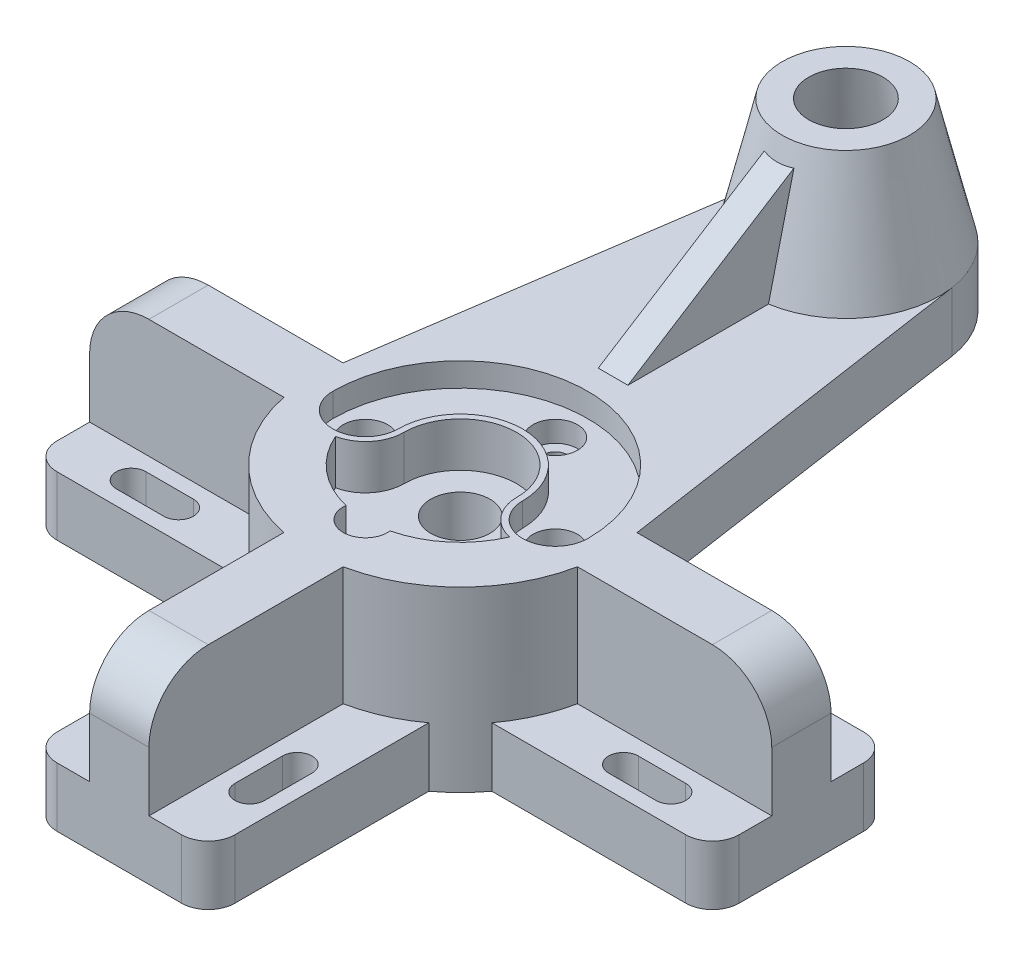
from build123d import *

# Parameters (mm, degrees)
SKETCH1_R                                     = 50.5
BOSS_EXTRUDE1_DEPTH                           = 60
SKETCH2_W                                     = 60
SKETCH2_H                                     = 115
BOSS_EXTRUDE2_DEPTH                           = 20
CIRPATTERN1_COUNT                             = 4
BOSS_EXTRUDE3_DEPTH                           = 20
FILLET1_R                                     = 9
BOSS_EXTRUDE4_DEPTH                           = 10
CIRPATTERN4_COUNT                             = 2
SKETCH9_W                                     = 20
SKETCH9_H                                     = 80
BOSS_EXTRUDE5_DEPTH                           = 40
FILLET2_R                                     = 20
CUT_EXTRUDE1_DEPTH                            = 8
CUT_EXTRUDE2_DEPTH                            = 203.255407839
CUT_EXTRUDE3_DEPTH                            = 15
CIRPATTERN5_COUNT                             = 4
SKETCH21_R                                    = 7.5
CUT_EXTRUDE4_DEPTH                            = 208.140652698
CUT_EXTRUDE4_DEPTH_BACK                       = 208.140652698
SKETCH22_R                                    = 10
CUT_EXTRUDE5_DEPTH                            = 204.303344783
CUT_EXTRUDE5_DEPTH_BACK                       = 204.303344783
CBORE_FOR_M12_HEX_HEAD_CAP_SCREW1_D           = 8
CBORE_FOR_M12_HEX_HEAD_CAP_SCREW1_CBORE_D     = 15
CBORE_FOR_M12_HEX_HEAD_CAP_SCREW1_CBORE_DEPTH = 7
RIB1_REACH                                    = 224.96
SKETCH17_WALL_W                               = 513.393885606
SKETCH17_WALL_H                               = 10


with BuildPart() as part:
    # Sketch1 → Boss-Extrude1 (new body)
    with BuildSketch(Plane(origin=(0, 0, 0), x_dir=(1, 0, 0), z_dir=(0, 1, 0))):
        with Locations(Location((0, 0, 0), (0, 0, 270))):
            Circle(SKETCH1_R)
    extrude(amount=BOSS_EXTRUDE1_DEPTH)

    # Sketch2 → Boss-Extrude2 (add)
    with BuildSketch(Plane.XZ):
        with Locations((0, 57.5)):
            Rectangle(SKETCH2_W, SKETCH2_H)
    boss_extrude2 = extrude(amount=-BOSS_EXTRUDE2_DEPTH)

    # CirPattern1: Boss-Extrude2 ×4 about axis, 1 skipped
    cirpattern1_axis = Axis((0, 0, 0), (0, -1, 0))
    add([boss_extrude2.rotate(cirpattern1_axis, i * 360 / CIRPATTERN1_COUNT) for i in range(1, CIRPATTERN1_COUNT) if i not in (2,)])

    # Sketch4 → Boss-Extrude3 (add)
    with BuildSketch(Plane(origin=(0, 60, 0), x_dir=(1, 0, 0), z_dir=(0, 1, 0))):
        with BuildLine():
            Line((-49.957724584, 7.380769231), (-31.161748998, 134.603846154))
            ThreePointArc((-31.161748998, 134.603846154), (0, 161.5), (31.161748998, 134.603846154))
            Line((31.161748998, 134.603846154), (49.957724584, 7.380769231))
            ThreePointArc((49.957724584, 7.380769231), (0, -50.5), (-49.957724584, 7.380769231))
        make_face()
    extrude(amount=-BOSS_EXTRUDE3_DEPTH)

    # Fillet1
    fillet1_edges = [part.edges().sort_by_distance(p)[0] for p in [
        (30, 10, 115),
        (-30, 10, 115),
        (-115, 10, 30),
        (-115, 10, -30),
        (115, 10, -30),
        (115, 10, 30),
    ]]
    fillet(fillet1_edges, radius=FILLET1_R)

    # Sketch8 → Boss-Extrude4 (add, symmetric)
    with BuildSketch(Plane.XY):
        with BuildLine():
            Line((-115, 20), (-115, 40))
            ThreePointArc((-115, 40), (-109.142135624, 54.142135624), (-95, 60))
            Line((-95, 60), (-45, 60))
            Line((-45, 60), (-45, 20))
            Line((-45, 20), (-115, 20))
        make_face()
    boss_extrude4 = extrude(amount=BOSS_EXTRUDE4_DEPTH, both=True)

    # CirPattern4: Boss-Extrude4 ×2 about axis
    cirpattern4_axis = Axis((0, -13.978729863, 0), (0, 1, 0))
    for i in range(1, CIRPATTERN4_COUNT):
        add(boss_extrude4.rotate(cirpattern4_axis, i * 360 / CIRPATTERN4_COUNT))

    # Sketch9 → Boss-Extrude5 (add)
    with BuildSketch(Plane(origin=(0, 20, 0), x_dir=(1, 0, 0), z_dir=(0, 1, 0))):
        with Locations((0, -75)):
            Rectangle(SKETCH9_W, SKETCH9_H)
    extrude(amount=BOSS_EXTRUDE5_DEPTH)

    # Fillet2
    fillet2_edges = [part.edges().sort_by_distance(p)[0] for p in [
        (0, 60, 115),
    ]]
    fillet(fillet2_edges, radius=FILLET2_R)

    # Sketch19 → Cut-Extrude1 (cut)
    with BuildSketch(Plane(origin=(0, 60, 0), x_dir=(1, 0, 0), z_dir=(0, 1, 0))):
        with BuildLine():
            ThreePointArc((-43, 0), (-32, -11), (-21, 0))
            ThreePointArc((-21, 0), (0, 21), (21, 0))
            ThreePointArc((21, 0), (32, -11), (43, 0))
            ThreePointArc((43, 0), (0, 43), (-43, 0))
        make_face()
    extrude(amount=-CUT_EXTRUDE1_DEPTH, mode=Mode.SUBTRACT)

    # Sketch6 → Cut-Extrude2 (cut, symmetric)
    with BuildSketch(Plane(origin=(0, 20, 0), x_dir=(1, 0, 0), z_dir=(0, 1, 0))):
        with BuildLine():
            Line((25, -75), (25, -91))
            ThreePointArc((25, -91), (20, -96), (15, -91))
            Line((15, -91), (15, -75))
            ThreePointArc((15, -75), (20, -70), (25, -75))
        make_face()
        with BuildLine():
            Line((-25, -75), (-25, -91))
            ThreePointArc((-25, -91), (-20, -96), (-15, -91))
            Line((-15, -91), (-15, -75))
            ThreePointArc((-15, -75), (-20, -70), (-25, -75))
        make_face()
    cut_extrude2 = extrude(amount=CUT_EXTRUDE2_DEPTH, both=True, mode=Mode.SUBTRACT)

    # Sketch20 → Cut-Extrude3 (cut)
    with BuildSketch(Plane(origin=(0, 60, 0), x_dir=(1, 0, 0), z_dir=(0, 1, 0))):
        with BuildLine():
            ThreePointArc((-19, 0), (0, 19), (19, 0))
            ThreePointArc((19, 0), (21.917140163, -8.205847762), (29.359375, -12.72898659))
            ThreePointArc((29.359375, -12.72898659), (0, -32), (-29.359375, -12.72898659))
            ThreePointArc((-29.359375, -12.72898659), (-21.917140163, -8.205847762), (-19, 0))
        make_face()
    extrude(amount=-CUT_EXTRUDE3_DEPTH, mode=Mode.SUBTRACT)

    # CirPattern5: Cut-Extrude2 ×4 about axis, 1 skipped
    cirpattern5_axis = Axis((0, 0, 0), (0, -1, 0))
    add([cut_extrude2.rotate(cirpattern5_axis, i * 360 / CIRPATTERN5_COUNT) for i in range(1, CIRPATTERN5_COUNT) if i not in (2,)], mode=Mode.SUBTRACT)

    # Sketch21 → Cut-Extrude4 (cut, two sides)
    with BuildSketch(Plane(origin=(0, 60, 0), x_dir=(1, 0, 0), z_dir=(0, 1, 0))) as cut_extrude4_sk:
        with Locations(Location((0, -32, 0), (0, 0, 270))):
            Circle(SKETCH21_R)
    extrude(amount=CUT_EXTRUDE4_DEPTH, mode=Mode.SUBTRACT)
    extrude(cut_extrude4_sk.sketch, amount=-CUT_EXTRUDE4_DEPTH_BACK, mode=Mode.SUBTRACT)

    # Sketch22 → Cut-Extrude5 (cut, two sides)
    with BuildSketch(Plane(origin=(0, 45, 0), x_dir=(1, 0, 0), z_dir=(0, 1, 0))) as cut_extrude5_sk:
        with Locations(Location((0, 0, 0), (0, 0, 270))):
            Circle(SKETCH22_R)
    extrude(amount=CUT_EXTRUDE5_DEPTH, mode=Mode.SUBTRACT)
    extrude(cut_extrude5_sk.sketch, amount=-CUT_EXTRUDE5_DEPTH_BACK, mode=Mode.SUBTRACT)

    # CBORE for M12 Hex Head Cap Screw1 (through all)
    with Locations(Plane(origin=(0, 52, 0), x_dir=(1, 0, 0), z_dir=(0, 1, 0))):
        with Locations((-32, 0), (32, 0), (0, 32)):
            CounterBoreHole(CBORE_FOR_M12_HEX_HEAD_CAP_SCREW1_D / 2, CBORE_FOR_M12_HEX_HEAD_CAP_SCREW1_CBORE_D / 2, CBORE_FOR_M12_HEX_HEAD_CAP_SCREW1_CBORE_DEPTH)

    # Sketch26 → Revolve1 (revolve)
    with BuildSketch(Plane(origin=(0, 0, 0), x_dir=(0, 0, -1), z_dir=(1, 0, 0))):
        Polygon((161.5, 60), (151.5, 102), (130, 102), (130, 60), align=None)
    revolve(axis=Axis((0, -4.416477213, -130), (0, 1, 0)))

    # Sketch17 wall → Rib1 (add, up to next)
    with BuildSketch(Plane(origin=(0, 77.5, -79.166666666), x_dir=(0, -0.534567509226, 0.845125776485), z_dir=(0, -0.845125776485, -0.534567509226)), mode=Mode.PRIVATE) as rib1_sk1:
        Rectangle(SKETCH17_WALL_W, SKETCH17_WALL_H)
    rib1_tool1 = extrude(rib1_sk1.sketch, amount=RIB1_REACH, mode=Mode.PRIVATE) - part.part
    add(rib1_tool1.solids().sort_by_distance((0, 77.5, -79.166666666))[0])

    # Sketch27 → Cut-Revolve1 (revolve, cut)
    with BuildSketch(Plane(origin=(0, 0, 0), x_dir=(0, 0, -1), z_dir=(1, 0, 0)), mode=Mode.PRIVATE) as cut_revolve1_sk:
        Polygon((142.5, 102), (152.5, 40), (130, 40), (130, 102), align=None)
    revolve(cut_revolve1_sk.sketch.rotate(Axis((0, 116.719168037, -130), (0, -1, 0)), 180), axis=Axis((0, 116.719168037, -130), (0, -1, 0)), mode=Mode.SUBTRACT)


solid = part.part
